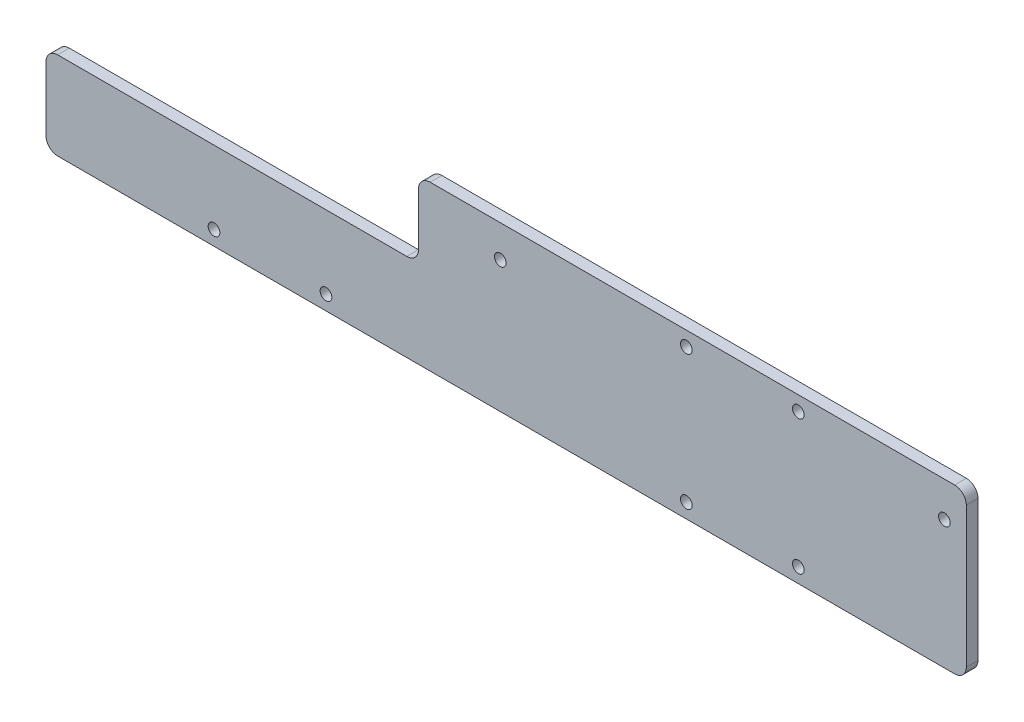
from build123d import *

# Parameters (mm, degrees)
SKETCH_1_R          = 2
EXTRUDE_1_DEPTH     = 4
EXTRUDE_3_DEPTH     = 4
SKETCH_7_R          = 2
CUT_EXTRUDE_2_DEPTH = 10


with BuildPart() as part:
    # 草图1 → 凸台-拉伸1 (new body)
    with BuildSketch(Plane.XY):
        with BuildLine():
            Line((-180.694062755, -12.410089261), (126.305937245, -12.410089261))
            ThreePointArc((126.305937245, -12.410089261), (129.13436437, -11.238516386), (130.305937245, -8.410089261))
            Line((130.305937245, -8.410089261), (130.305937245, 7.71191214))
            Line((130.305937245, 7.71191214), (130.305937245, 17.589910739))
            Line((130.305937245, 17.589910739), (130.305937245, 39.589910739))
            ThreePointArc((130.305937245, 39.589910739), (129.13436437, 42.418337863), (126.305937245, 43.589910739))
            Line((126.305937245, 43.589910739), (-23.194062755, 43.589910739))
            ThreePointArc((-23.194062755, 43.589910739), (-26.022489879, 42.418337863), (-27.194062755, 39.589910739))
            Line((-27.194062755, 39.589910739), (-27.194062755, 27.589910739))
            ThreePointArc((-27.194062755, 27.589910739), (-30.122994943, 20.518842927), (-37.194062755, 17.589910739))
            Line((-37.194062755, 17.589910739), (-180.694062755, 17.589910739))
            ThreePointArc((-180.694062755, 17.589910739), (-183.522489879, 16.418337863), (-184.694062755, 13.589910739))
            Line((-184.694062755, 13.589910739), (-184.694062755, -8.410089261))
            ThreePointArc((-184.694062755, -8.410089261), (-183.522489879, -11.238516386), (-180.694062755, -12.410089261))
        make_face()
        with Locations((-127.194062755, -7.410089261)):
            Circle(SKETCH_1_R, mode=Mode.SUBTRACT)
        with Locations((-88.864062755, -7.410089261)):
            Circle(SKETCH_1_R, mode=Mode.SUBTRACT)
        with Locations((34.475937245, -7.410089261)):
            Circle(SKETCH_1_R, mode=Mode.SUBTRACT)
        with Locations((72.805937245, -7.410089261)):
            Circle(SKETCH_1_R, mode=Mode.SUBTRACT)
        with Locations((34.475937245, 38.589910739)):
            Circle(SKETCH_1_R, mode=Mode.SUBTRACT)
        with Locations((122.805937245, 31.589910739)):
            Circle(SKETCH_1_R, mode=Mode.SUBTRACT)
        with Locations((72.805937245, 38.589910739)):
            Circle(SKETCH_1_R, mode=Mode.SUBTRACT)
    extrude(amount=EXTRUDE_1_DEPTH)

    # 草图2 → 凸台-拉伸3 (add)
    with BuildSketch(Plane(origin=(0, 0, 0), x_dir=(-1, 0, 0), z_dir=(0, 0, -1))):
        with BuildLine():
            Line((53.194062755, 43.589910739), (23.194062755, 43.589910739))
            Line((23.194062755, 43.589910739), (23.194062755, 17.589910739))
            Line((23.194062755, 17.589910739), (57.194062755, 17.589910739))
            Line((57.194062755, 17.589910739), (61.194062755, 17.589910739))
            ThreePointArc((61.194062755, 17.589910739), (58.36563563, 18.761483614), (57.194062755, 21.589910739))
            Line((57.194062755, 21.589910739), (57.194062755, 39.589910739))
            ThreePointArc((57.194062755, 39.589910739), (56.022489879, 42.418337863), (53.194062755, 43.589910739))
        make_face()
    extrude(amount=-EXTRUDE_3_DEPTH)

    # 草图7 → 切除-拉伸2 (cut)
    with BuildSketch(Plane(origin=(0, 0, 0), x_dir=(-1, 0, 0), z_dir=(0, 0, -1))):
        with Locations((29.194062755, 32.589910739)):
            Circle(SKETCH_7_R)
    extrude(amount=-CUT_EXTRUDE_2_DEPTH, mode=Mode.SUBTRACT)


solid = part.part
